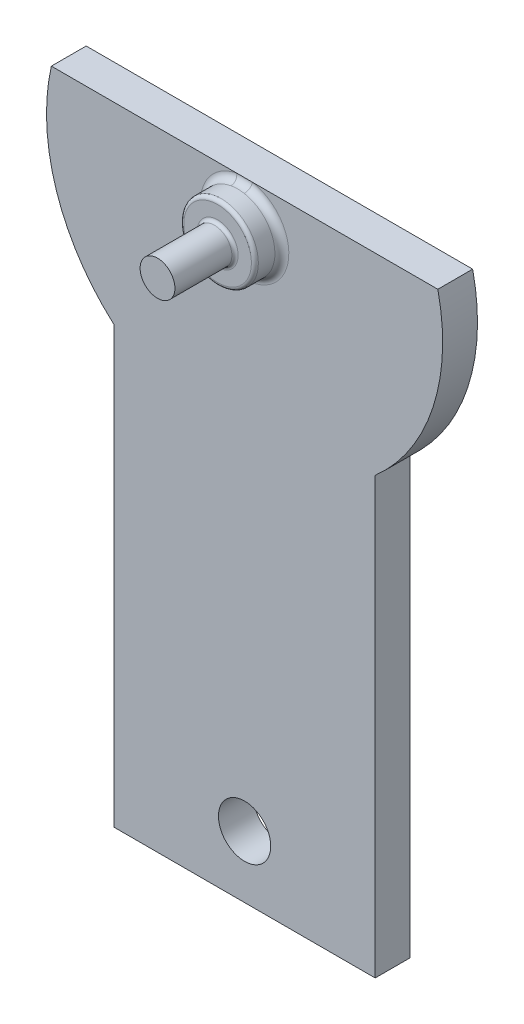
from build123d import *

# Parameters (mm, degrees)
BOSS_EXTRUDE1_DEPTH = 20
BOSS_EXTRUDE2_START = 20
SKETCH1_3_R         = 10
BOSS_EXTRUDE2_DEPTH = 50
SKETCH2_R           = 15
CUT_EXTRUDE1_DEPTH  = 20
SKETCH3_R           = 21.409884381
BOSS_EXTRUDE3_DEPTH = 15.5
FILLET1_R           = 1.8
FILLET2_R           = 4
FILLET3_R           = 2


with BuildPart() as part:
    # Sketch1 → Boss-Extrude1 (new body)
    with BuildSketch(Plane.XY):
        with BuildLine():
            Line((-75, -335.522292415), (75, -335.522292415))
            Line((75, -335.522292415), (75, -85.522292415))
            ThreePointArc((75, -85.522292415), (108.166019919, -35.201912374), (110.9687456, 25))
            Line((110.9687456, 25), (-110.9687456, 25))
            ThreePointArc((-110.9687456, 25), (-108.166019919, -35.201912374), (-75, -85.522292415))
            Line((-75, -85.522292415), (-75, -335.522292415))
        make_face()
    extrude(amount=BOSS_EXTRUDE1_DEPTH)

    # Sketch1_3 → Boss-Extrude2 (add)
    with BuildSketch(Plane.XY.offset(BOSS_EXTRUDE2_START)):
        Circle(SKETCH1_3_R)
    extrude(amount=BOSS_EXTRUDE2_DEPTH)

    # Sketch2 → Cut-Extrude1 (cut)
    with BuildSketch(Plane.XY.offset(20)):
        with Locations((0, -300)):
            Circle(SKETCH2_R)
    extrude(amount=-CUT_EXTRUDE1_DEPTH, mode=Mode.SUBTRACT)

    # Sketch3 → Boss-Extrude3 (add)
    with BuildSketch(Plane.XY.offset(20)):
        Circle(SKETCH3_R)
    extrude(amount=BOSS_EXTRUDE3_DEPTH)

    # Fillet1
    fillet1_edges = [part.edges().sort_by_distance(p)[0] for p in [
        (-10, 0, 35.5),
    ]]
    fillet(fillet1_edges, radius=FILLET1_R)

    # Fillet2
    fillet2_edges = [part.edges().sort_by_distance(p)[0] for p in [
        (-21.409884381, 0, 20),
    ]]
    fillet(fillet2_edges, radius=FILLET2_R)

    # Fillet3
    fillet3_edges = [part.edges().sort_by_distance(p)[0] for p in [
        (-21.409884381, 0, 35.5),
    ]]
    fillet(fillet3_edges, radius=FILLET3_R)


solid = part.part
